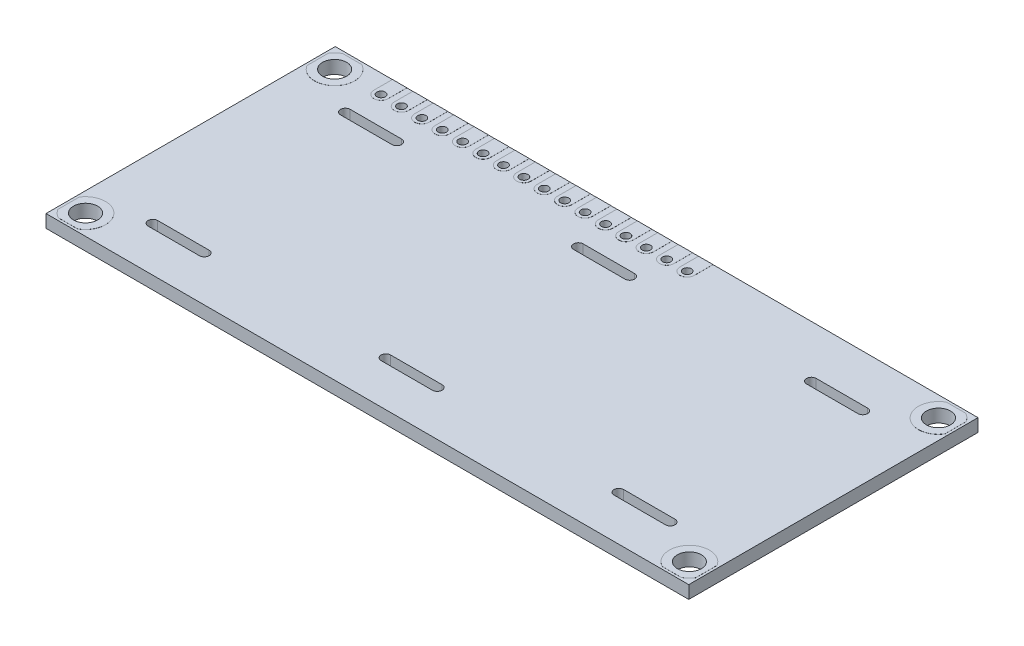
from build123d import *

# Parameters (mm, degrees)
ESQUISSE1_W        = 80
ESQUISSE1_H        = 36
ESQUISSE1_R        = 1.5
ESQUISSE1_R_2      = 0.52
BOSS_EXTRU_1_DEPTH = 1.6
ESQUISSE2_R        = 1.5
ESQUISSE2_R_2      = 0.52
BOSS_EXTRU_2_DEPTH = 0.01
BOSS_EXTRU_3_START = -1.6
ESQUISSE2_2_R      = 1.5
ESQUISSE2_2_R_2    = 0.52
BOSS_EXTRU_3_DEPTH = 0.01


with BuildPart() as part:
    # Esquisse1 → Boss.-Extru.1 (new body)
    with BuildSketch(Plane(origin=(0, 0, 0), x_dir=(1, 0, 0), z_dir=(0, 1, 0))):
        with Locations((40, 18)):
            Rectangle(ESQUISSE1_W, ESQUISSE1_H)
        with Locations((2.42, 33.5)):
            Circle(ESQUISSE1_R, mode=Mode.SUBTRACT)
        with Locations((2.42, 2.5)):
            Circle(ESQUISSE1_R, mode=Mode.SUBTRACT)
        with Locations((77.58, 2.5)):
            Circle(ESQUISSE1_R, mode=Mode.SUBTRACT)
        with Locations((77.58, 33.5)):
            Circle(ESQUISSE1_R, mode=Mode.SUBTRACT)
        with Locations((8.02, 33.68)):
            Circle(ESQUISSE1_R_2, mode=Mode.SUBTRACT)
        with Locations((10.56, 33.68)):
            Circle(ESQUISSE1_R_2, mode=Mode.SUBTRACT)
        with Locations((13.1, 33.68)):
            Circle(ESQUISSE1_R_2, mode=Mode.SUBTRACT)
        with Locations((15.64, 33.68)):
            Circle(ESQUISSE1_R_2, mode=Mode.SUBTRACT)
        with Locations((18.18, 33.68)):
            Circle(ESQUISSE1_R_2, mode=Mode.SUBTRACT)
        with Locations((20.72, 33.68)):
            Circle(ESQUISSE1_R_2, mode=Mode.SUBTRACT)
        with Locations((23.26, 33.68)):
            Circle(ESQUISSE1_R_2, mode=Mode.SUBTRACT)
        with Locations((25.8, 33.68)):
            Circle(ESQUISSE1_R_2, mode=Mode.SUBTRACT)
        with Locations((28.34, 33.68)):
            Circle(ESQUISSE1_R_2, mode=Mode.SUBTRACT)
        with Locations((30.88, 33.68)):
            Circle(ESQUISSE1_R_2, mode=Mode.SUBTRACT)
        with Locations((33.42, 33.68)):
            Circle(ESQUISSE1_R_2, mode=Mode.SUBTRACT)
        with Locations((35.96, 33.68)):
            Circle(ESQUISSE1_R_2, mode=Mode.SUBTRACT)
        with Locations((38.5, 33.68)):
            Circle(ESQUISSE1_R_2, mode=Mode.SUBTRACT)
        with Locations((41.04, 33.68)):
            Circle(ESQUISSE1_R_2, mode=Mode.SUBTRACT)
        with Locations((43.58, 33.68)):
            Circle(ESQUISSE1_R_2, mode=Mode.SUBTRACT)
        with Locations((46.12, 33.68)):
            Circle(ESQUISSE1_R_2, mode=Mode.SUBTRACT)
        with BuildLine():
            Line((7.7, 30.16), (14.1, 30.16))
            ThreePointArc((14.1, 30.16), (14.7, 29.56), (14.1, 28.96))
            Line((14.1, 28.96), (7.7, 28.96))
            ThreePointArc((7.7, 28.96), (7.1, 29.56), (7.7, 30.16))
        make_face(mode=Mode.SUBTRACT)
        with BuildLine():
            Line((7.7, 6.2), (14.1, 6.2))
            ThreePointArc((14.1, 6.2), (14.7, 5.6), (14.1, 5))
            Line((14.1, 5), (7.7, 5))
            ThreePointArc((7.7, 5), (7.1, 5.6), (7.7, 6.2))
        make_face(mode=Mode.SUBTRACT)
        with BuildLine():
            Line((36.7, 30.16), (43.1, 30.16))
            ThreePointArc((43.1, 30.16), (43.7, 29.56), (43.1, 28.96))
            Line((43.1, 28.96), (36.7, 28.96))
            ThreePointArc((36.7, 28.96), (36.1, 29.56), (36.7, 30.16))
        make_face(mode=Mode.SUBTRACT)
        with BuildLine():
            Line((36.7, 6.2), (43.1, 6.2))
            ThreePointArc((43.1, 6.2), (43.7, 5.6), (43.1, 5))
            Line((43.1, 5), (36.7, 5))
            ThreePointArc((36.7, 5), (36.1, 5.6), (36.7, 6.2))
        make_face(mode=Mode.SUBTRACT)
        with BuildLine():
            Line((65.7, 30.16), (72.1, 30.16))
            ThreePointArc((72.1, 30.16), (72.7, 29.56), (72.1, 28.96))
            Line((72.1, 28.96), (65.7, 28.96))
            ThreePointArc((65.7, 28.96), (65.1, 29.56), (65.7, 30.16))
        make_face(mode=Mode.SUBTRACT)
        with BuildLine():
            Line((65.7, 6.2), (72.1, 6.2))
            ThreePointArc((72.1, 6.2), (72.7, 5.6), (72.1, 5))
            Line((72.1, 5), (65.7, 5))
            ThreePointArc((65.7, 5), (65.1, 5.6), (65.7, 6.2))
        make_face(mode=Mode.SUBTRACT)
    extrude(amount=BOSS_EXTRU_1_DEPTH)

    # Esquisse2 → Boss.-Extru.2 (add)
    with BuildSketch(Plane(origin=(0, 1.6, 0), x_dir=(1, 0, 0), z_dir=(0, 1, 0))):
        with BuildLine():
            Line((0.3, 32.175009434), (0.3, 34.824990566))
            ThreePointArc((0.3, 34.824990566), (0.709388811, 35.323131745), (1.232565791, 35.7))
            Line((1.232565791, 35.7), (3.607434209, 35.7))
            ThreePointArc((3.607434209, 35.7), (4.243131745, 31.789388811), (0.3, 32.175009434))
        make_face()
        with Locations((2.42, 33.5)):
            Circle(ESQUISSE2_R, mode=Mode.SUBTRACT)
        with BuildLine():
            Line((7.12, 33.68), (7.12, 36))
            Line((7.12, 36), (8.92, 36))
            Line((8.92, 36), (8.92, 33.68))
            ThreePointArc((8.92, 33.68), (8.02, 32.78), (7.12, 33.68))
        make_face()
        with Locations((8.02, 33.68)):
            Circle(ESQUISSE2_R_2, mode=Mode.SUBTRACT)
        with BuildLine():
            Line((3.607434209, 0.3), (1.232565791, 0.3))
            ThreePointArc((1.232565791, 0.3), (0.709388811, 0.676868255), (0.3, 1.175009434))
            Line((0.3, 1.175009434), (0.3, 3.824990566))
            ThreePointArc((0.3, 3.824990566), (4.243131745, 4.210611189), (3.607434209, 0.3))
        make_face()
        with Locations((2.42, 2.5)):
            Circle(ESQUISSE2_R, mode=Mode.SUBTRACT)
        with BuildLine():
            Line((76.392565791, 0.3), (78.767434209, 0.3))
            ThreePointArc((78.767434209, 0.3), (79.290611189, 0.676868255), (79.7, 1.175009434))
            Line((79.7, 1.175009434), (79.7, 3.824990566))
            ThreePointArc((79.7, 3.824990566), (75.756868255, 4.210611189), (76.392565791, 0.3))
        make_face()
        with Locations((77.58, 2.5)):
            Circle(ESQUISSE2_R, mode=Mode.SUBTRACT)
        with BuildLine():
            Line((79.7, 32.175009434), (79.7, 34.824990566))
            ThreePointArc((79.7, 34.824990566), (79.290611189, 35.323131745), (78.767434209, 35.7))
            Line((78.767434209, 35.7), (76.392565791, 35.7))
            ThreePointArc((76.392565791, 35.7), (75.756868255, 31.789388811), (79.7, 32.175009434))
        make_face()
        with Locations((77.58, 33.5)):
            Circle(ESQUISSE2_R, mode=Mode.SUBTRACT)
        with BuildLine():
            Line((9.66, 33.68), (9.66, 36))
            Line((9.66, 36), (11.46, 36))
            Line((11.46, 36), (11.46, 33.68))
            ThreePointArc((11.46, 33.68), (10.56, 32.78), (9.66, 33.68))
        make_face()
        with Locations((10.56, 33.68)):
            Circle(ESQUISSE2_R_2, mode=Mode.SUBTRACT)
        with BuildLine():
            Line((12.2, 33.68), (12.2, 36))
            Line((12.2, 36), (14, 36))
            Line((14, 36), (14, 33.68))
            ThreePointArc((14, 33.68), (13.1, 32.78), (12.2, 33.68))
        make_face()
        with Locations((13.1, 33.68)):
            Circle(ESQUISSE2_R_2, mode=Mode.SUBTRACT)
        with BuildLine():
            Line((14.74, 33.68), (14.74, 36))
            Line((14.74, 36), (16.54, 36))
            Line((16.54, 36), (16.54, 33.68))
            ThreePointArc((16.54, 33.68), (15.64, 32.78), (14.74, 33.68))
        make_face()
        with Locations((15.64, 33.68)):
            Circle(ESQUISSE2_R_2, mode=Mode.SUBTRACT)
        with BuildLine():
            Line((17.28, 33.68), (17.28, 36))
            Line((17.28, 36), (19.08, 36))
            Line((19.08, 36), (19.08, 33.68))
            ThreePointArc((19.08, 33.68), (18.18, 32.78), (17.28, 33.68))
        make_face()
        with Locations((18.18, 33.68)):
            Circle(ESQUISSE2_R_2, mode=Mode.SUBTRACT)
        with BuildLine():
            Line((19.82, 33.68), (19.82, 36))
            Line((19.82, 36), (21.62, 36))
            Line((21.62, 36), (21.62, 33.68))
            ThreePointArc((21.62, 33.68), (20.72, 32.78), (19.82, 33.68))
        make_face()
        with Locations((20.72, 33.68)):
            Circle(ESQUISSE2_R_2, mode=Mode.SUBTRACT)
        with BuildLine():
            Line((22.36, 33.68), (22.36, 36))
            Line((22.36, 36), (24.16, 36))
            Line((24.16, 36), (24.16, 33.68))
            ThreePointArc((24.16, 33.68), (23.26, 32.78), (22.36, 33.68))
        make_face()
        with Locations((23.26, 33.68)):
            Circle(ESQUISSE2_R_2, mode=Mode.SUBTRACT)
        with BuildLine():
            Line((24.9, 33.68), (24.9, 36))
            Line((24.9, 36), (26.7, 36))
            Line((26.7, 36), (26.7, 33.68))
            ThreePointArc((26.7, 33.68), (25.8, 32.78), (24.9, 33.68))
        make_face()
        with Locations((25.8, 33.68)):
            Circle(ESQUISSE2_R_2, mode=Mode.SUBTRACT)
        with BuildLine():
            Line((27.44, 33.68), (27.44, 36))
            Line((27.44, 36), (29.24, 36))
            Line((29.24, 36), (29.24, 33.68))
            ThreePointArc((29.24, 33.68), (28.34, 32.78), (27.44, 33.68))
        make_face()
        with Locations((28.34, 33.68)):
            Circle(ESQUISSE2_R_2, mode=Mode.SUBTRACT)
        with BuildLine():
            Line((29.98, 33.68), (29.98, 36))
            Line((29.98, 36), (31.78, 36))
            Line((31.78, 36), (31.78, 33.68))
            ThreePointArc((31.78, 33.68), (30.88, 32.78), (29.98, 33.68))
        make_face()
        with Locations((30.88, 33.68)):
            Circle(ESQUISSE2_R_2, mode=Mode.SUBTRACT)
        with BuildLine():
            Line((32.52, 33.68), (32.52, 36))
            Line((32.52, 36), (34.32, 36))
            Line((34.32, 36), (34.32, 33.68))
            ThreePointArc((34.32, 33.68), (33.42, 32.78), (32.52, 33.68))
        make_face()
        with Locations((33.42, 33.68)):
            Circle(ESQUISSE2_R_2, mode=Mode.SUBTRACT)
        with BuildLine():
            Line((35.06, 33.68), (35.06, 36))
            Line((35.06, 36), (36.86, 36))
            Line((36.86, 36), (36.86, 33.68))
            ThreePointArc((36.86, 33.68), (35.96, 32.78), (35.06, 33.68))
        make_face()
        with Locations((35.96, 33.68)):
            Circle(ESQUISSE2_R_2, mode=Mode.SUBTRACT)
        with BuildLine():
            Line((37.6, 33.68), (37.6, 36))
            Line((37.6, 36), (39.4, 36))
            Line((39.4, 36), (39.4, 33.68))
            ThreePointArc((39.4, 33.68), (38.5, 32.78), (37.6, 33.68))
        make_face()
        with Locations((38.5, 33.68)):
            Circle(ESQUISSE2_R_2, mode=Mode.SUBTRACT)
        with BuildLine():
            Line((40.14, 33.68), (40.14, 36))
            Line((40.14, 36), (41.94, 36))
            Line((41.94, 36), (41.94, 33.68))
            ThreePointArc((41.94, 33.68), (41.04, 32.78), (40.14, 33.68))
        make_face()
        with Locations((41.04, 33.68)):
            Circle(ESQUISSE2_R_2, mode=Mode.SUBTRACT)
        with BuildLine():
            Line((42.68, 33.68), (42.68, 36))
            Line((42.68, 36), (44.48, 36))
            Line((44.48, 36), (44.48, 33.68))
            ThreePointArc((44.48, 33.68), (43.58, 32.78), (42.68, 33.68))
        make_face()
        with Locations((43.58, 33.68)):
            Circle(ESQUISSE2_R_2, mode=Mode.SUBTRACT)
        with BuildLine():
            Line((45.22, 33.68), (45.22, 36))
            Line((45.22, 36), (47.02, 36))
            Line((47.02, 36), (47.02, 33.68))
            ThreePointArc((47.02, 33.68), (46.12, 32.78), (45.22, 33.68))
        make_face()
        with Locations((46.12, 33.68)):
            Circle(ESQUISSE2_R_2, mode=Mode.SUBTRACT)
    extrude(amount=BOSS_EXTRU_2_DEPTH)

    # Esquisse2_2 → Boss.-Extru.3 (add)
    with BuildSketch(Plane(origin=(0, 1.6, 0), x_dir=(1, 0, 0), z_dir=(0, 1, 0)).offset(BOSS_EXTRU_3_START)):
        with BuildLine():
            Line((0.3, 32.175009434), (0.3, 34.824990566))
            ThreePointArc((0.3, 34.824990566), (0.709388811, 35.323131745), (1.232565791, 35.7))
            Line((1.232565791, 35.7), (3.607434209, 35.7))
            ThreePointArc((3.607434209, 35.7), (4.243131745, 31.789388811), (0.3, 32.175009434))
        make_face()
        with Locations((2.42, 33.5)):
            Circle(ESQUISSE2_2_R, mode=Mode.SUBTRACT)
        with BuildLine():
            Line((7.12, 33.68), (7.12, 36))
            Line((7.12, 36), (8.92, 36))
            Line((8.92, 36), (8.92, 33.68))
            ThreePointArc((8.92, 33.68), (8.02, 32.78), (7.12, 33.68))
        make_face()
        with Locations((8.02, 33.68)):
            Circle(ESQUISSE2_2_R_2, mode=Mode.SUBTRACT)
        with BuildLine():
            Line((3.607434209, 0.3), (1.232565791, 0.3))
            ThreePointArc((1.232565791, 0.3), (0.709388811, 0.676868255), (0.3, 1.175009434))
            Line((0.3, 1.175009434), (0.3, 3.824990566))
            ThreePointArc((0.3, 3.824990566), (4.243131745, 4.210611189), (3.607434209, 0.3))
        make_face()
        with Locations((2.42, 2.5)):
            Circle(ESQUISSE2_2_R, mode=Mode.SUBTRACT)
        with BuildLine():
            Line((76.392565791, 0.3), (78.767434209, 0.3))
            ThreePointArc((78.767434209, 0.3), (79.290611189, 0.676868255), (79.7, 1.175009434))
            Line((79.7, 1.175009434), (79.7, 3.824990566))
            ThreePointArc((79.7, 3.824990566), (75.756868255, 4.210611189), (76.392565791, 0.3))
        make_face()
        with Locations((77.58, 2.5)):
            Circle(ESQUISSE2_2_R, mode=Mode.SUBTRACT)
        with BuildLine():
            Line((79.7, 32.175009434), (79.7, 34.824990566))
            ThreePointArc((79.7, 34.824990566), (79.290611189, 35.323131745), (78.767434209, 35.7))
            Line((78.767434209, 35.7), (76.392565791, 35.7))
            ThreePointArc((76.392565791, 35.7), (75.756868255, 31.789388811), (79.7, 32.175009434))
        make_face()
        with Locations((77.58, 33.5)):
            Circle(ESQUISSE2_2_R, mode=Mode.SUBTRACT)
        with BuildLine():
            Line((9.66, 33.68), (9.66, 36))
            Line((9.66, 36), (11.46, 36))
            Line((11.46, 36), (11.46, 33.68))
            ThreePointArc((11.46, 33.68), (10.56, 32.78), (9.66, 33.68))
        make_face()
        with Locations((10.56, 33.68)):
            Circle(ESQUISSE2_2_R_2, mode=Mode.SUBTRACT)
        with BuildLine():
            Line((12.2, 33.68), (12.2, 36))
            Line((12.2, 36), (14, 36))
            Line((14, 36), (14, 33.68))
            ThreePointArc((14, 33.68), (13.1, 32.78), (12.2, 33.68))
        make_face()
        with Locations((13.1, 33.68)):
            Circle(ESQUISSE2_2_R_2, mode=Mode.SUBTRACT)
        with BuildLine():
            Line((14.74, 33.68), (14.74, 36))
            Line((14.74, 36), (16.54, 36))
            Line((16.54, 36), (16.54, 33.68))
            ThreePointArc((16.54, 33.68), (15.64, 32.78), (14.74, 33.68))
        make_face()
        with Locations((15.64, 33.68)):
            Circle(ESQUISSE2_2_R_2, mode=Mode.SUBTRACT)
        with BuildLine():
            Line((17.28, 33.68), (17.28, 36))
            Line((17.28, 36), (19.08, 36))
            Line((19.08, 36), (19.08, 33.68))
            ThreePointArc((19.08, 33.68), (18.18, 32.78), (17.28, 33.68))
        make_face()
        with Locations((18.18, 33.68)):
            Circle(ESQUISSE2_2_R_2, mode=Mode.SUBTRACT)
        with BuildLine():
            Line((19.82, 33.68), (19.82, 36))
            Line((19.82, 36), (21.62, 36))
            Line((21.62, 36), (21.62, 33.68))
            ThreePointArc((21.62, 33.68), (20.72, 32.78), (19.82, 33.68))
        make_face()
        with Locations((20.72, 33.68)):
            Circle(ESQUISSE2_2_R_2, mode=Mode.SUBTRACT)
        with BuildLine():
            Line((22.36, 33.68), (22.36, 36))
            Line((22.36, 36), (24.16, 36))
            Line((24.16, 36), (24.16, 33.68))
            ThreePointArc((24.16, 33.68), (23.26, 32.78), (22.36, 33.68))
        make_face()
        with Locations((23.26, 33.68)):
            Circle(ESQUISSE2_2_R_2, mode=Mode.SUBTRACT)
        with BuildLine():
            Line((24.9, 33.68), (24.9, 36))
            Line((24.9, 36), (26.7, 36))
            Line((26.7, 36), (26.7, 33.68))
            ThreePointArc((26.7, 33.68), (25.8, 32.78), (24.9, 33.68))
        make_face()
        with Locations((25.8, 33.68)):
            Circle(ESQUISSE2_2_R_2, mode=Mode.SUBTRACT)
        with BuildLine():
            Line((27.44, 33.68), (27.44, 36))
            Line((27.44, 36), (29.24, 36))
            Line((29.24, 36), (29.24, 33.68))
            ThreePointArc((29.24, 33.68), (28.34, 32.78), (27.44, 33.68))
        make_face()
        with Locations((28.34, 33.68)):
            Circle(ESQUISSE2_2_R_2, mode=Mode.SUBTRACT)
        with BuildLine():
            Line((29.98, 33.68), (29.98, 36))
            Line((29.98, 36), (31.78, 36))
            Line((31.78, 36), (31.78, 33.68))
            ThreePointArc((31.78, 33.68), (30.88, 32.78), (29.98, 33.68))
        make_face()
        with Locations((30.88, 33.68)):
            Circle(ESQUISSE2_2_R_2, mode=Mode.SUBTRACT)
        with BuildLine():
            Line((32.52, 33.68), (32.52, 36))
            Line((32.52, 36), (34.32, 36))
            Line((34.32, 36), (34.32, 33.68))
            ThreePointArc((34.32, 33.68), (33.42, 32.78), (32.52, 33.68))
        make_face()
        with Locations((33.42, 33.68)):
            Circle(ESQUISSE2_2_R_2, mode=Mode.SUBTRACT)
        with BuildLine():
            Line((35.06, 33.68), (35.06, 36))
            Line((35.06, 36), (36.86, 36))
            Line((36.86, 36), (36.86, 33.68))
            ThreePointArc((36.86, 33.68), (35.96, 32.78), (35.06, 33.68))
        make_face()
        with Locations((35.96, 33.68)):
            Circle(ESQUISSE2_2_R_2, mode=Mode.SUBTRACT)
        with BuildLine():
            Line((37.6, 33.68), (37.6, 36))
            Line((37.6, 36), (39.4, 36))
            Line((39.4, 36), (39.4, 33.68))
            ThreePointArc((39.4, 33.68), (38.5, 32.78), (37.6, 33.68))
        make_face()
        with Locations((38.5, 33.68)):
            Circle(ESQUISSE2_2_R_2, mode=Mode.SUBTRACT)
        with BuildLine():
            Line((40.14, 33.68), (40.14, 36))
            Line((40.14, 36), (41.94, 36))
            Line((41.94, 36), (41.94, 33.68))
            ThreePointArc((41.94, 33.68), (41.04, 32.78), (40.14, 33.68))
        make_face()
        with Locations((41.04, 33.68)):
            Circle(ESQUISSE2_2_R_2, mode=Mode.SUBTRACT)
        with BuildLine():
            Line((42.68, 33.68), (42.68, 36))
            Line((42.68, 36), (44.48, 36))
            Line((44.48, 36), (44.48, 33.68))
            ThreePointArc((44.48, 33.68), (43.58, 32.78), (42.68, 33.68))
        make_face()
        with Locations((43.58, 33.68)):
            Circle(ESQUISSE2_2_R_2, mode=Mode.SUBTRACT)
        with BuildLine():
            Line((45.22, 33.68), (45.22, 36))
            Line((45.22, 36), (47.02, 36))
            Line((47.02, 36), (47.02, 33.68))
            ThreePointArc((47.02, 33.68), (46.12, 32.78), (45.22, 33.68))
        make_face()
        with Locations((46.12, 33.68)):
            Circle(ESQUISSE2_2_R_2, mode=Mode.SUBTRACT)
    extrude(amount=-BOSS_EXTRU_3_DEPTH)

    # Esquisse3 → R_volution1 (revolve)
    with BuildSketch(Plane(origin=(0, 0, -18), x_dir=(-1, 0, 0), z_dir=(0, 0, -1))):
        with BuildLine():
            Line((-54, 0), (-54, -1.2))
            ThreePointArc((-54, -1.2), (-51.06347805, -0.894792675), (-48.25, 0))
            Line((-48.25, 0), (-54, 0))
        make_face()
    revolve(axis=Axis((54, -12.033839249, -18), (0, 1, 0)))

    # Esquisse3_6 → R_volution2 (revolve)
    with BuildSketch(Plane(origin=(0, 0, -18), x_dir=(-1, 0, 0), z_dir=(0, 0, -1))):
        with BuildLine():
            Line((-27.5, 0), (-27.5, -1.2))
            ThreePointArc((-27.5, -1.2), (-24.072081535, -0.897666363), (-20.75, 0))
            Line((-20.75, 0), (-27.5, 0))
        make_face()
    revolve(axis=Axis((27.5, 0, -18), (0, -1, 0)))


solid = part.part
